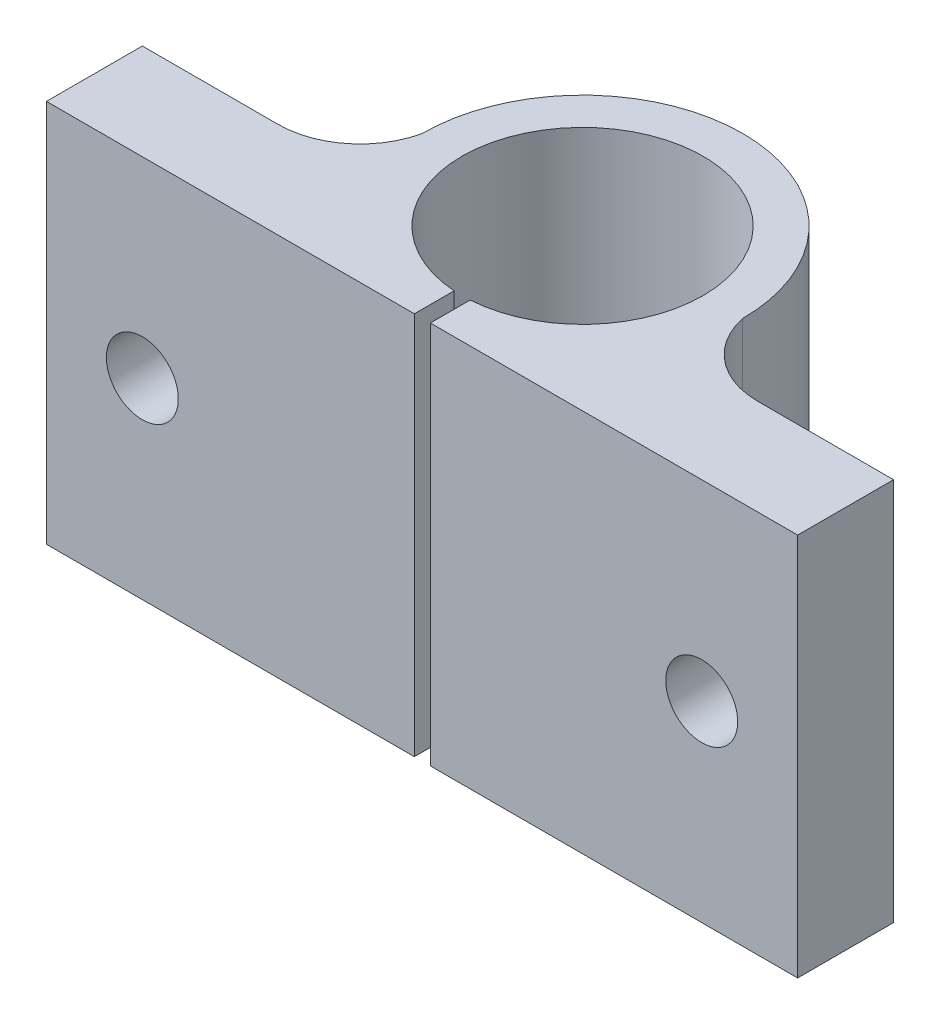
from build123d import *

# Parameters (mm, degrees)
BOSS_EXTRUDE1_DEPTH        = 24
CUT_EXTRUDE1_DEPTH         = 25
SKETCH3_W                  = 7.55
SKETCH3_H                  = 24
F_4_5_4_5_DIAMETER_HOLE1_D = 4.5


with BuildPart() as part:
    # Sketch1 → Boss-Extrude1 (new body)
    with BuildSketch(Plane(origin=(0, 24, 0), x_dir=(1, 0, 0), z_dir=(0, 1, 0))):
        with BuildLine():
            Line((0, 0), (47, 0))
            Line((47, 0), (47, 6))
            Line((47, 6), (38.5, 6))
            ThreePointArc((38.5, 6), (35.307693119, 7.131854655), (33.541354656, 10.021831577))
            ThreePointArc((33.541354656, 10.021831577), (23.505747016, 20.045434485), (13.49594739, 9.996059012))
            ThreePointArc((13.49594739, 9.996059012), (11.698748894, 7.121907302), (8.5, 6))
            Line((8.5, 6), (0, 6))
            Line((0, 6), (0, 0))
        make_face()
    extrude(amount=-BOSS_EXTRUDE1_DEPTH)

    # Sketch2 → Cut-Extrude1 (cut, through all)
    with BuildSketch(Plane.XZ):
        with BuildLine():
            Line((24.018633311, 0), (23.018633311, 0))
            Line((23.018633311, 0), (23.018633311, -2.489295869))
            ThreePointArc((23.018633311, -2.489295869), (23.518633311, -2.472721384), (24.018633311, -2.489295869))
            Line((24.018633311, -2.489295869), (24.018633311, 0))
        make_face()
    extrude(amount=-CUT_EXTRUDE1_DEPTH, mode=Mode.SUBTRACT)

    # Sketch3 → Cut-Revolve1 (revolve, cut)
    with BuildSketch(Plane(origin=(0, 0, -10.022721384), x_dir=(-1, 0, 0), z_dir=(0, 0, -1))):
        with Locations((-27.293633311, 12)):
            Rectangle(SKETCH3_W, SKETCH3_H)
    revolve(axis=Axis((23.518633311, 0, -10.022721384), (0, 1, 0)), mode=Mode.SUBTRACT)

    # Ø4.5 (4.5) Diameter Hole1 (through all)
    with Locations(Plane(origin=(0, 0, -6), x_dir=(-1, 0, 0), z_dir=(0, 0, -1))):
        with Locations((-41, 12), (-6, 12)):
            Hole(F_4_5_4_5_DIAMETER_HOLE1_D / 2)


solid = part.part
